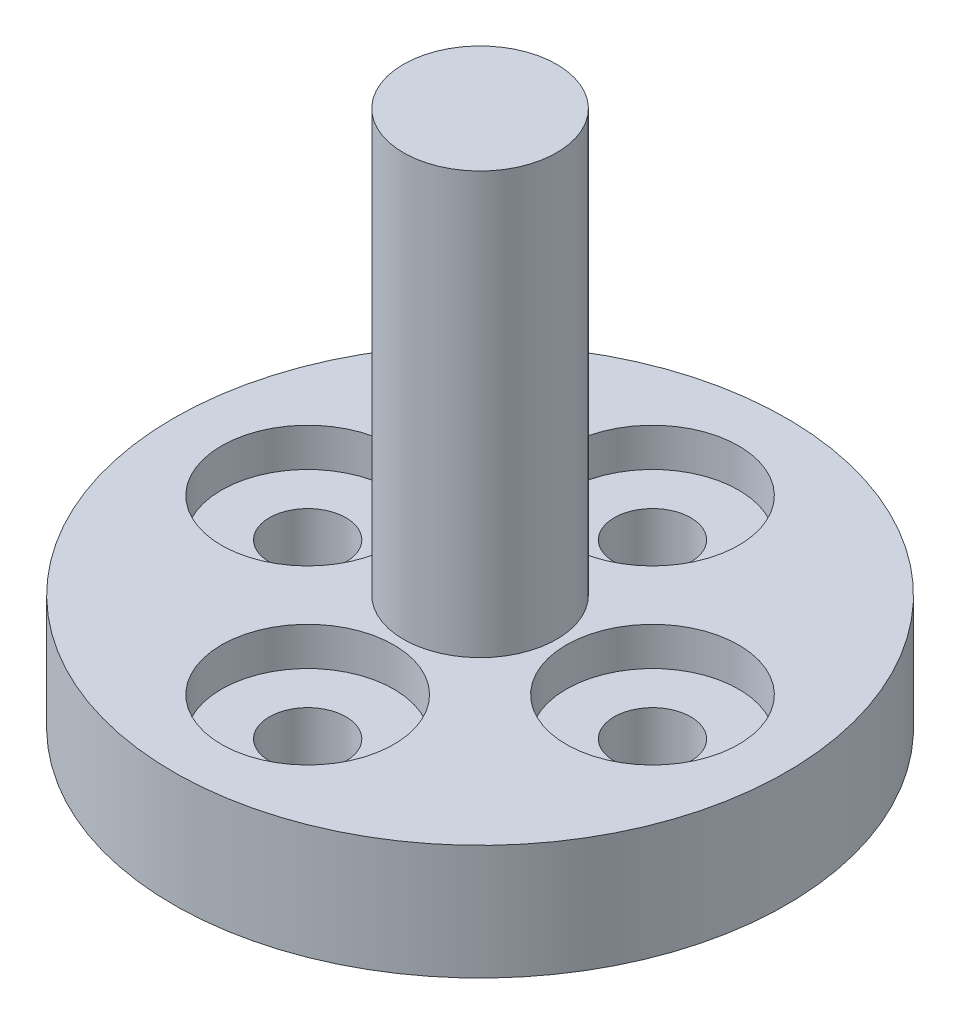
from build123d import *

# Parameters (mm, degrees)
SKETCH3_R          = 1
CUT_EXTRUDE1_DEPTH = 4
SKETCH4_R          = 2.25
CUT_EXTRUDE2_DEPTH = 1


with BuildPart() as part:
    # Sketch1 → Revolve1 (revolve)
    with BuildSketch(Plane.XY):
        Polygon((0, 0), (8, 0), (8, 3), (2, 3), (2, 14), (0, 14), align=None)
    revolve(axis=Axis((0, 14, 0), (0, -1, 0)))

    # Sketch3 → Cut-Extrude1 (cut, through all)
    with BuildSketch(Plane(origin=(0, 3, 0), x_dir=(1, 0, 0), z_dir=(0, 1, 0))):
        with Locations((0, 4.5)):
            Circle(SKETCH3_R)
        with Locations((4.5, 0)):
            Circle(SKETCH3_R)
        with Locations((0, -4.5)):
            Circle(SKETCH3_R)
        with Locations((-4.5, 0)):
            Circle(SKETCH3_R)
    extrude(amount=-CUT_EXTRUDE1_DEPTH, mode=Mode.SUBTRACT)

    # Sketch4 → Cut-Extrude2 (cut)
    with BuildSketch(Plane(origin=(0, 3, 0), x_dir=(1, 0, 0), z_dir=(0, 1, 0))):
        with Locations((0, 4.5)):
            Circle(SKETCH4_R)
        with Locations((4.5, 0)):
            Circle(SKETCH4_R)
        with Locations((0, -4.5)):
            Circle(SKETCH4_R)
        with Locations((-4.5, 0)):
            Circle(SKETCH4_R)
    extrude(amount=-CUT_EXTRUDE2_DEPTH, mode=Mode.SUBTRACT)


solid = part.part
